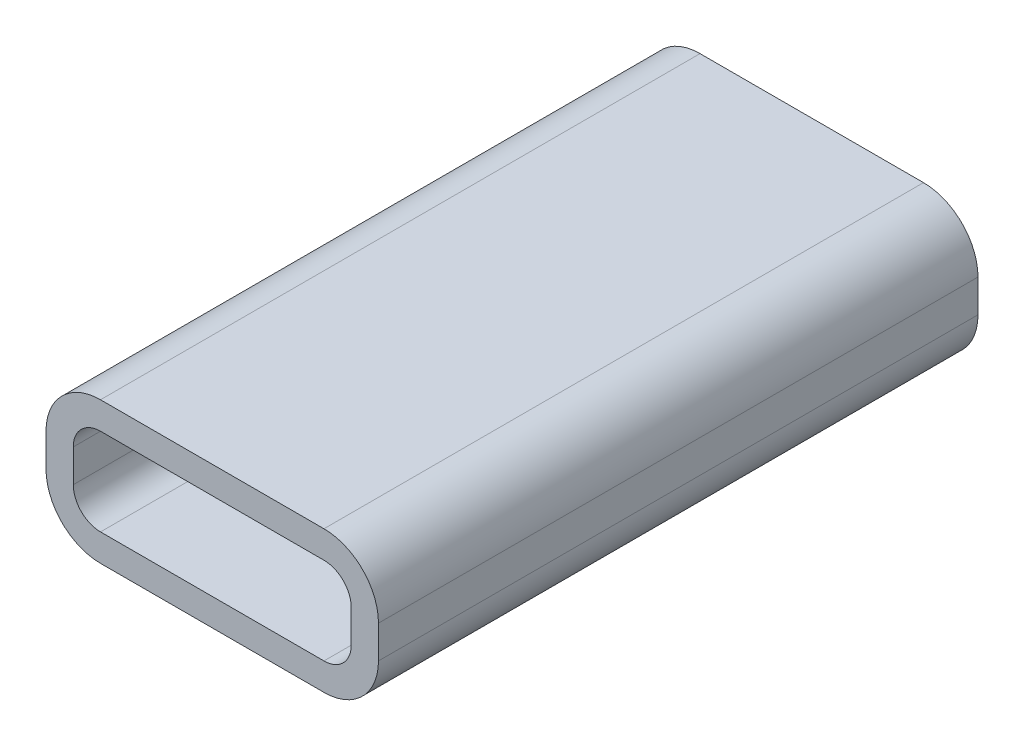
from build123d import *

# Parameters (mm, degrees)
BOSS_EXTRU_2_DEPTH = 10
BOSS_EXTRU_3_DEPTH = 1


with BuildPart() as part:
    # Esquisse1 → Boss.-Extru.2 (new body)
    with BuildSketch(Plane.XY):
        with BuildLine():
            Line((-4.1, 2.6), (4.1, 2.6))
            ThreePointArc((4.1, 2.6), (5.514213562, 2.014213562), (6.1, 0.6))
            Line((6.1, 0.6), (6.1, -0.6))
            ThreePointArc((6.1, -0.6), (5.514213562, -2.014213562), (4.1, -2.6))
            Line((4.1, -2.6), (-4.1, -2.6))
            ThreePointArc((-4.1, -2.6), (-5.514213562, -2.014213562), (-6.1, -0.6))
            Line((-6.1, -0.6), (-6.1, 0.6))
            ThreePointArc((-6.1, 0.6), (-5.514213562, 2.014213562), (-4.1, 2.6))
        make_face()
        with BuildLine():
            Line((-4.1, 1.6), (4.1, 1.6))
            ThreePointArc((4.1, 1.6), (4.807106781, 1.307106781), (5.1, 0.6))
            Line((5.1, 0.6), (5.1, -0.6))
            ThreePointArc((5.1, -0.6), (4.807106781, -1.307106781), (4.1, -1.6))
            Line((4.1, -1.6), (-4.1, -1.6))
            ThreePointArc((-4.1, -1.6), (-4.807106781, -1.307106781), (-5.1, -0.6))
            Line((-5.1, -0.6), (-5.1, 0.6))
            ThreePointArc((-5.1, 0.6), (-4.807106781, 1.307106781), (-4.1, 1.6))
        make_face(mode=Mode.SUBTRACT)
    boss_extru_2 = extrude(amount=BOSS_EXTRU_2_DEPTH)

    # Esquisse2 → Boss.-Extru.3 (add)
    with BuildSketch(Plane(origin=(0, 0, 0), x_dir=(-1, 0, 0), z_dir=(0, 0, -1))):
        with BuildLine():
            Line((4.1, 2.6), (-4.1, 2.6))
            ThreePointArc((-4.1, 2.6), (-5.514213562, 2.014213562), (-6.1, 0.6))
            Line((-6.1, 0.6), (-6.1, -0.6))
            ThreePointArc((-6.1, -0.6), (-5.514213562, -2.014213562), (-4.1, -2.6))
            Line((-4.1, -2.6), (4.1, -2.6))
            ThreePointArc((4.1, -2.6), (5.514213562, -2.014213562), (6.1, -0.6))
            Line((6.1, -0.6), (6.1, 0.6))
            ThreePointArc((6.1, 0.6), (5.514213562, 2.014213562), (4.1, 2.6))
        make_face()
    boss_extru_3 = extrude(amount=BOSS_EXTRU_3_DEPTH)

    # Symétrie1: Boss.-Extru.2, Boss.-Extru.3 across plane
    add(boss_extru_2.mirror(Plane(origin=(-4.1, 0.6, -1), x_dir=(1, 0, 0), z_dir=(0, 0, -1))))
    add(boss_extru_3.mirror(Plane(origin=(-4.1, 0.6, -1), x_dir=(1, 0, 0), z_dir=(0, 0, -1))))


solid = part.part
